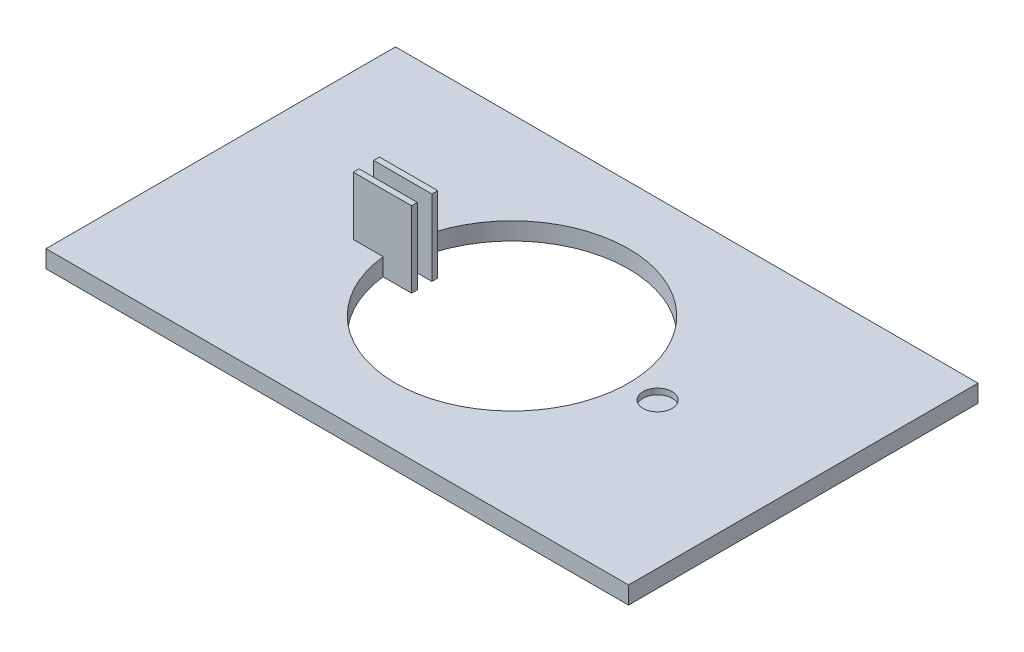
from build123d import *

# Parameters (mm, degrees)
CROQUIS1_W                   = 100
CROQUIS1_H                   = 60
CROQUIS1_R                   = 20
SALIENTE_EXTRUIR1_DEPTH      = 3
CROQUIS2_W                   = 10
CROQUIS2_H                   = 1
SALIENTE_EXTRUIR2_DEPTH      = 10
SALIENTE_EXTRUIR2_DEPTH_BACK = 3
CROQUIS3_R                   = 2.5
CORTAR_EXTRUIR1_DEPTH        = 1


with BuildPart() as part:
    # Croquis1 → Saliente-Extruir1 (new body)
    with BuildSketch(Plane(origin=(0, 0, 0), x_dir=(1, 0, 0), z_dir=(0, 1, 0))):
        Rectangle(CROQUIS1_W, CROQUIS1_H)
        Circle(CROQUIS1_R, mode=Mode.SUBTRACT)
    extrude(amount=SALIENTE_EXTRUIR1_DEPTH)

    # Croquis2 → Saliente-Extruir2 (add, two sides)
    with BuildSketch(Plane(origin=(0, 3, 0), x_dir=(1, 0, 0), z_dir=(0, 1, 0))) as saliente_extruir2_sk:
        with Locations((-20, 1.75)):
            Rectangle(CROQUIS2_W, CROQUIS2_H)
        with Locations((-20, -1.75)):
            Rectangle(CROQUIS2_W, CROQUIS2_H)
    extrude(amount=SALIENTE_EXTRUIR2_DEPTH)
    extrude(saliente_extruir2_sk.sketch, amount=-SALIENTE_EXTRUIR2_DEPTH_BACK)

    # Croquis3 → Cortar-Extruir1 (cut)
    with BuildSketch(Plane(origin=(0, 3, 0), x_dir=(1, 0, 0), z_dir=(0, 1, 0))):
        with Locations((25, 0)):
            Circle(CROQUIS3_R)
    extrude(amount=-CORTAR_EXTRUIR1_DEPTH, mode=Mode.SUBTRACT)


solid = part.part
